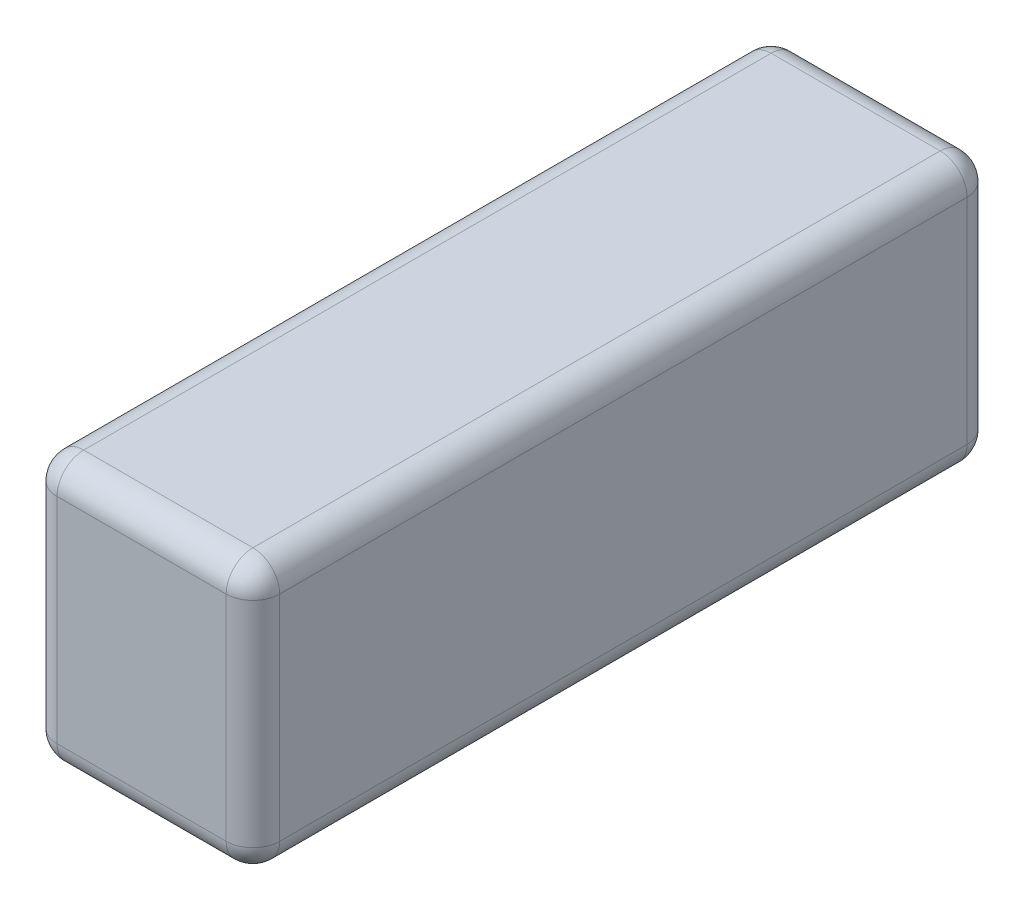
from build123d import *

# Parameters (mm, degrees)
SKETCH1_W           = 43.942
SKETCH1_H           = 15.875
BOSS_EXTRUDE1_DEPTH = 13.208
FILLET1_R           = 1.5875


with BuildPart() as part:
    # Sketch1 → Boss-Extrude1 (new body)
    with BuildSketch(Plane(origin=(0, 0, 0), x_dir=(0, 0, -1), z_dir=(1, 0, 0))):
        Rectangle(SKETCH1_W, SKETCH1_H)
    extrude(amount=BOSS_EXTRUDE1_DEPTH)

    # Fillet1
    fillet1_edges = [part.edges().sort_by_distance(p)[0] for p in [
        (13.208, 0, -21.971),
        (13.208, 7.9375, 0),
        (13.208, 0, 21.971),
        (0, 7.9375, 0),
        (0, 0, -21.971),
        (0, -7.9375, 0),
        (0, 0, 21.971),
        (6.604, 7.9375, 21.971),
        (6.604, 7.9375, -21.971),
        (6.604, -7.9375, -21.971),
        (6.604, -7.9375, 21.971),
        (13.208, -7.9375, 0),
    ]]
    fillet(fillet1_edges, radius=FILLET1_R)


solid = part.part
